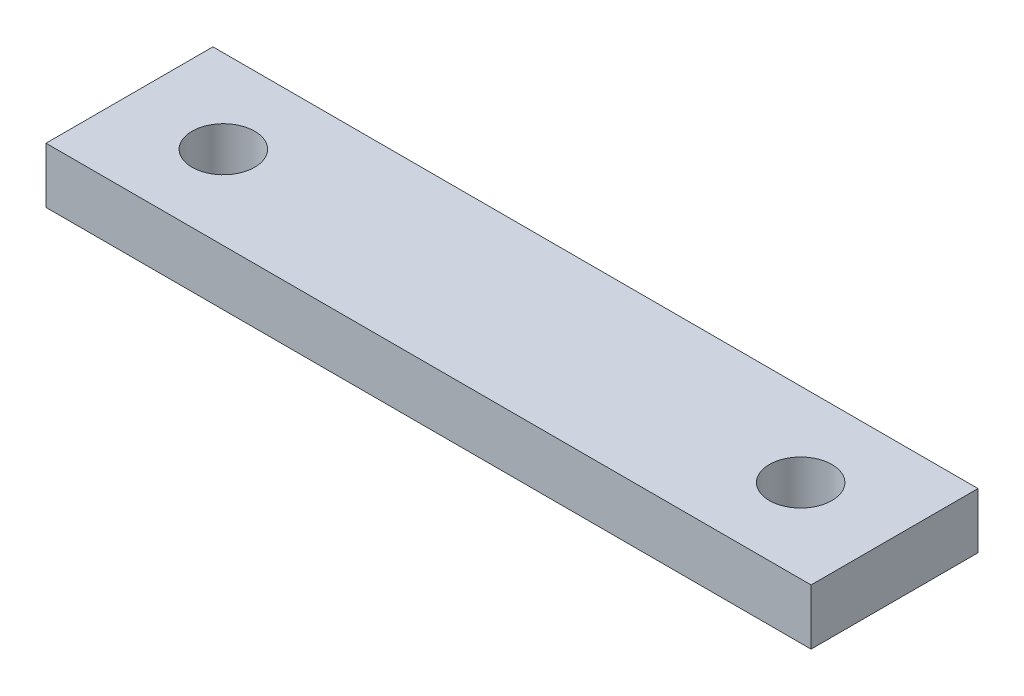
from build123d import *

# Parameters (mm, degrees)
SKETCH_1_W      = 55
SKETCH_1_H      = 12
SKETCH_1_R      = 2.25
EXTRUDE_1_DEPTH = 4


with BuildPart() as part:
    # 草图1 → 凸台-拉伸1 (new body)
    with BuildSketch(Plane(origin=(0, 0, 0), x_dir=(1, 0, 0), z_dir=(0, 1, 0))):
        Rectangle(SKETCH_1_W, SKETCH_1_H)
        with Locations((-20.75, 0)):
            Circle(SKETCH_1_R, mode=Mode.SUBTRACT)
        with Locations((20.75, 0)):
            Circle(SKETCH_1_R, mode=Mode.SUBTRACT)
    extrude(amount=EXTRUDE_1_DEPTH)


solid = part.part
